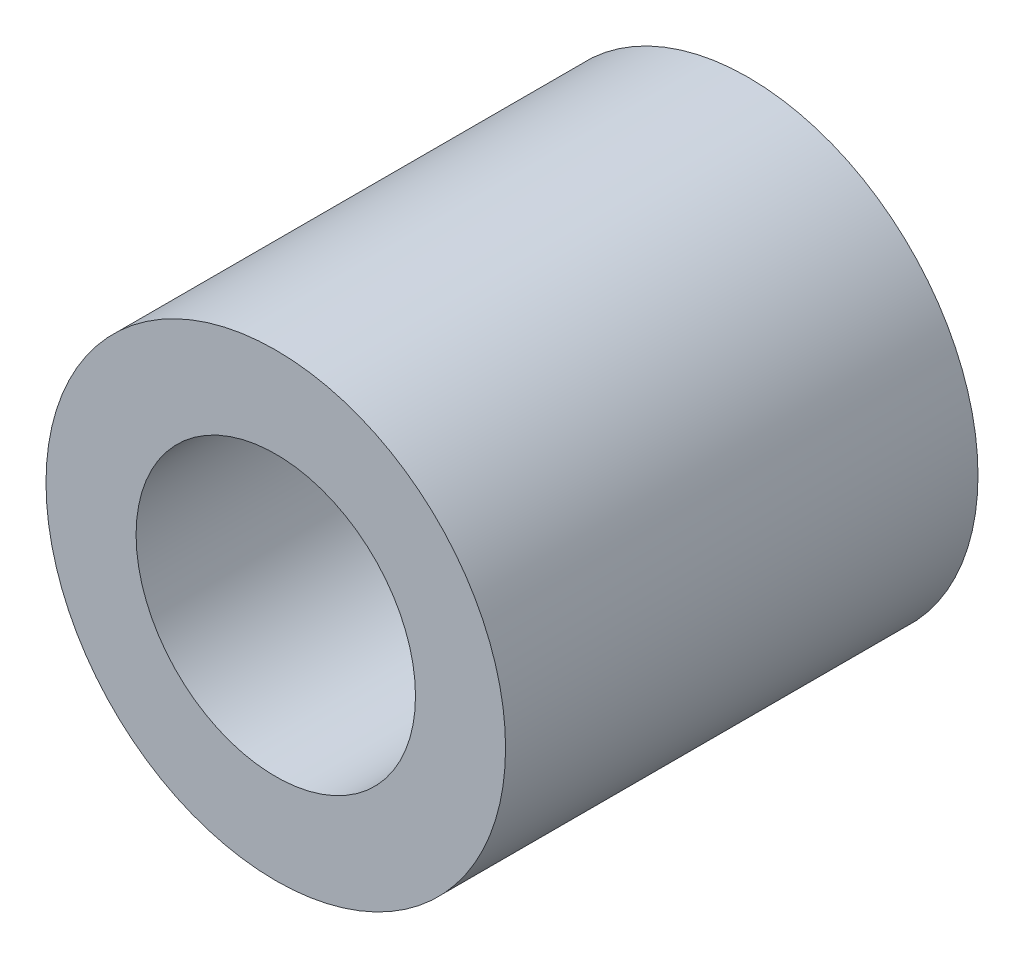
from build123d import *

# Parameters (mm, degrees)
SKETCH1_R           = 12.5
SKETCH1_R_2         = 7.6
BOSS_EXTRUDE1_DEPTH = 25.7


with BuildPart() as part:
    # Sketch1 → Boss-Extrude1 (new body)
    with BuildSketch(Plane.XY):
        Circle(SKETCH1_R)
        Circle(SKETCH1_R_2, mode=Mode.SUBTRACT)
    extrude(amount=BOSS_EXTRUDE1_DEPTH)


solid = part.part
